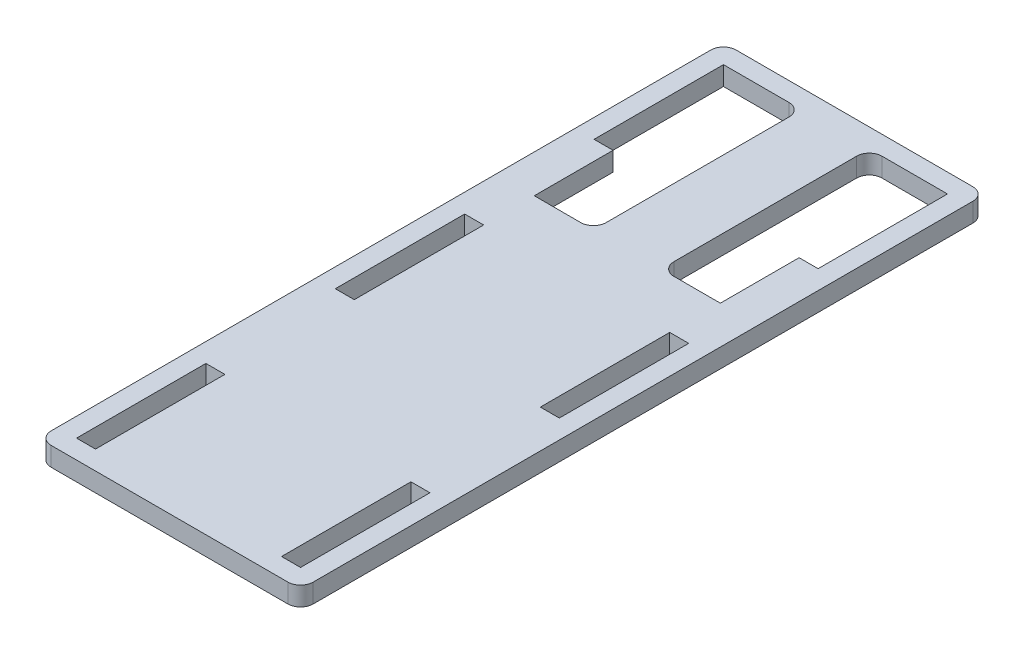
from build123d import *

# Parameters (mm, degrees)
SKETCH1_W               = 41.4
SKETCH1_H               = 108.224
SKETCH1_W_2             = 3
SKETCH1_H_2             = 20.4448
BOSS_EXTRUDE1_DEPTH     = 3
CUT_EXTRUDE1_DEPTH      = 1
CUT_EXTRUDE1_DEPTH_BACK = 4
FILLET1_R               = 2


with BuildPart() as part:
    # Sketch1 → Boss-Extrude1 (new body)
    with BuildSketch(Plane(origin=(0, 0, 0), x_dir=(1, 0, 0), z_dir=(0, 1, 0))):
        Rectangle(SKETCH1_W, SKETCH1_H)
        with Locations((16.2, 40.8896)):
            Rectangle(SKETCH1_W_2, SKETCH1_H_2, mode=Mode.SUBTRACT)
        with Locations((16.2, 0)):
            Rectangle(SKETCH1_W_2, SKETCH1_H_2, mode=Mode.SUBTRACT)
        with Locations((16.2, -40.8896)):
            Rectangle(SKETCH1_W_2, SKETCH1_H_2, mode=Mode.SUBTRACT)
        with Locations((-16.2, -40.8896)):
            Rectangle(SKETCH1_W_2, SKETCH1_H_2, mode=Mode.SUBTRACT)
        with Locations((-16.2, 0)):
            Rectangle(SKETCH1_W_2, SKETCH1_H_2, mode=Mode.SUBTRACT)
        with Locations((-16.2, 40.8896)):
            Rectangle(SKETCH1_W_2, SKETCH1_H_2, mode=Mode.SUBTRACT)
    extrude(amount=BOSS_EXTRUDE1_DEPTH)

    # Sketch2 → Cut-Extrude1 (cut, two sides)
    with BuildSketch(Plane(origin=(0, 3, 0), x_dir=(1, 0, 0), z_dir=(0, 1, 0))) as cut_extrude1_sk:
        Polygon((-5.35, 51.112), (-14.7, 51.112), (-14.7, 30.6672), (-14.7, 18.2224), (-5.35, 18.2224), align=None)
        Polygon((14.7, 51.112), (5.35, 51.112), (5.35, 18.2224), (14.7, 18.2224), (14.7, 30.6672), align=None)
    extrude(amount=CUT_EXTRUDE1_DEPTH, mode=Mode.SUBTRACT)
    extrude(cut_extrude1_sk.sketch, amount=-CUT_EXTRUDE1_DEPTH_BACK, mode=Mode.SUBTRACT)

    # Fillet1
    fillet1_edges = [part.edges().sort_by_distance(p)[0] for p in [
        (-5.35, 1.5, -18.2224),
        (-5.35, 1.5, -51.112),
        (5.35, 1.5, -18.2224),
        (5.35, 1.5, -51.112),
        (20.7, 1.5, 54.112),
        (-20.7, 1.5, 54.112),
        (-20.7, 1.5, -54.112),
        (20.7, 1.5, -54.112),
    ]]
    fillet(fillet1_edges, radius=FILLET1_R)


solid = part.part
